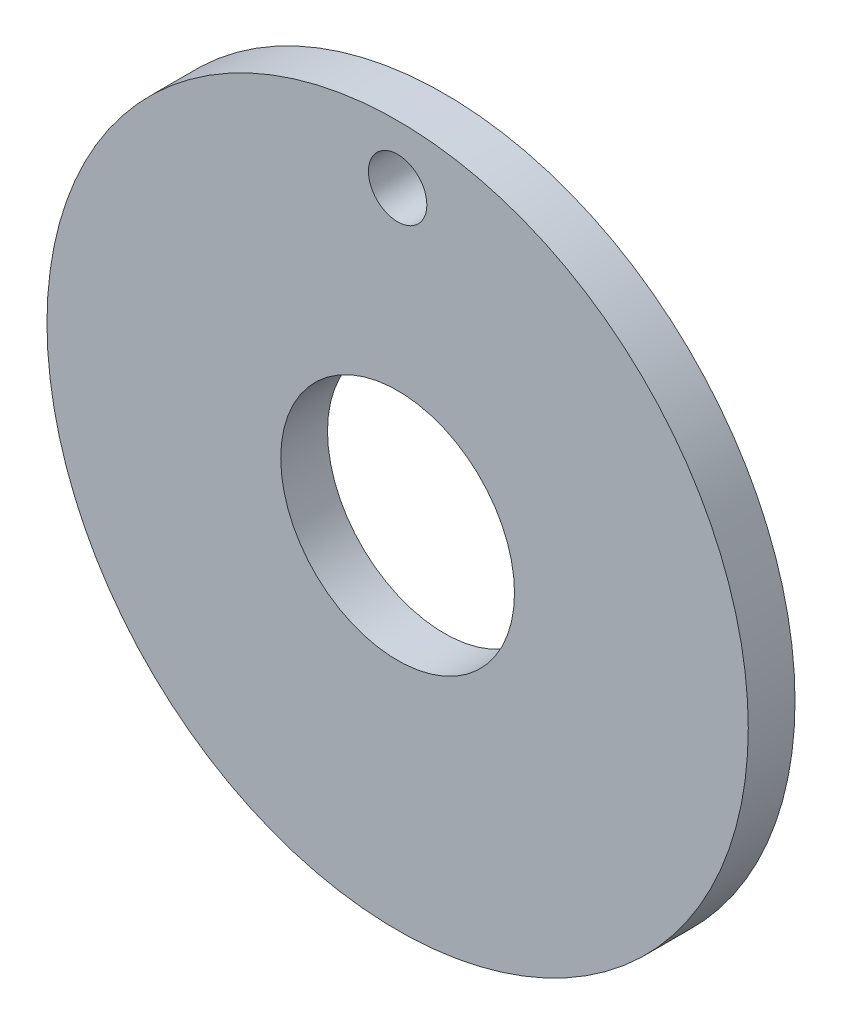
from build123d import *

# Parameters (mm, degrees)
SKETCH1_R           = 19.05
SKETCH1_R_2         = 6.35
BOSS_EXTRUDE1_DEPTH = 2.54
SKETCH2_R           = 1.5875
CUT_EXTRUDE1_DEPTH  = 3.54


with BuildPart() as part:
    # Sketch1 → Boss-Extrude1 (new body)
    with BuildSketch(Plane.XY):
        Circle(SKETCH1_R)
        Circle(SKETCH1_R_2, mode=Mode.SUBTRACT)
    extrude(amount=BOSS_EXTRUDE1_DEPTH)

    # Sketch2 → Cut-Extrude1 (cut, through all)
    with BuildSketch(Plane.XY.offset(2.54)):
        with Locations((0, 15.875)):
            Circle(SKETCH2_R)
    extrude(amount=-CUT_EXTRUDE1_DEPTH, mode=Mode.SUBTRACT)


solid = part.part
